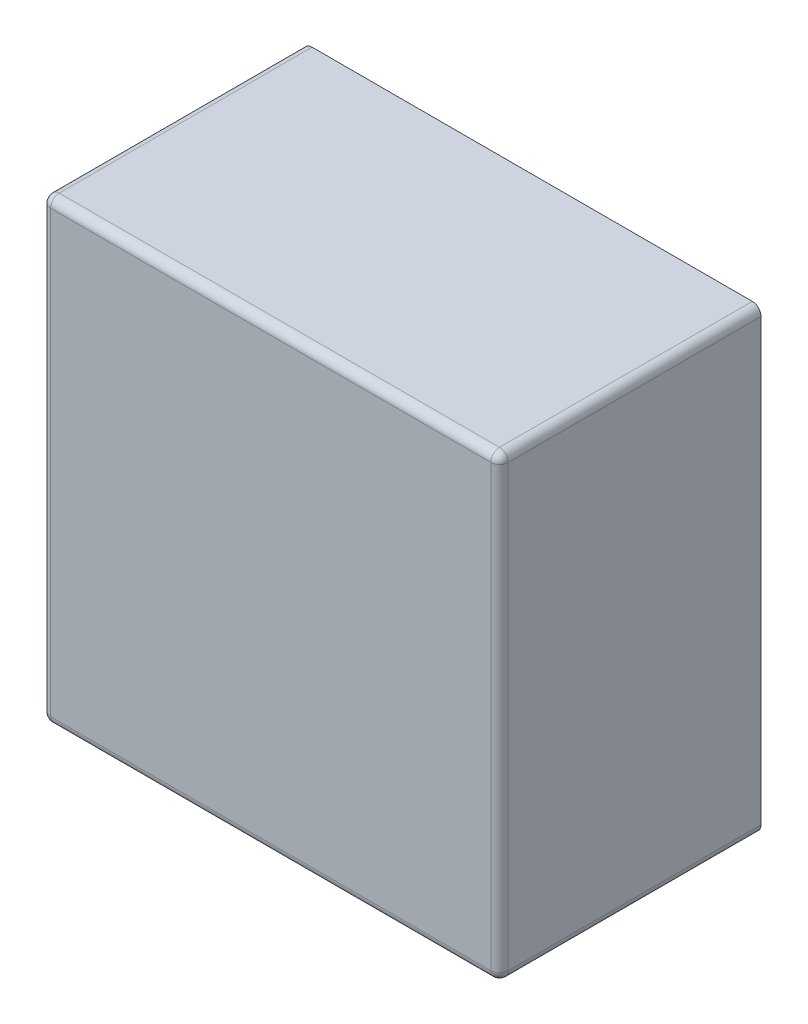
from build123d import *

# Parameters (mm, degrees)
CROQUIS1_W              = 105
CROQUIS1_H              = 105
SALIENTE_EXTRUIR1_DEPTH = 60
REDONDEO1_R             = 2


with BuildPart() as part:
    # Croquis1 → Saliente-Extruir1 (new body)
    with BuildSketch(Plane.XY):
        with Locations((52.5, -52.5)):
            Rectangle(CROQUIS1_W, CROQUIS1_H)
    extrude(amount=SALIENTE_EXTRUIR1_DEPTH)

    # Redondeo1
    redondeo1_edges = [part.edges().sort_by_distance(p)[0] for p in [
        (105, -52.5, 60),
        (52.5, 0, 60),
        (0, -52.5, 60),
        (52.5, -105, 60),
        (0, 0, 30),
        (105, 0, 30),
        (105, -105, 30),
        (0, -105, 30),
    ]]
    fillet(redondeo1_edges, radius=REDONDEO1_R)


solid = part.part
